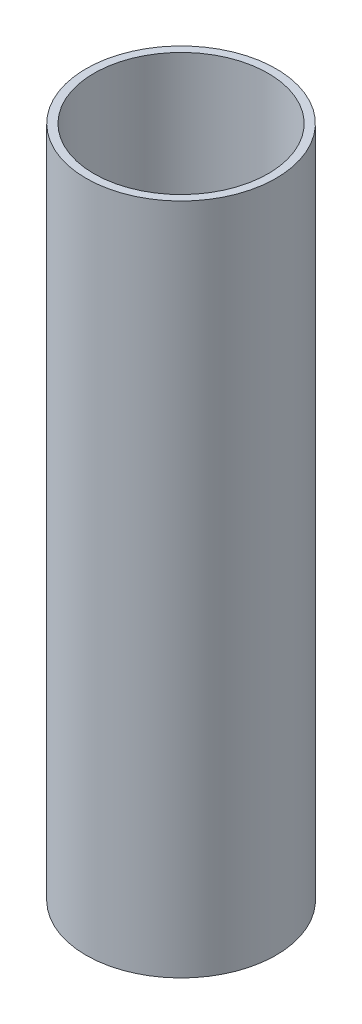
from build123d import *

# Parameters (mm, degrees)
SKETCH3_R           = 12
SKETCH3_R_2         = 11
BOSS_EXTRUDE3_DEPTH = 85


with BuildPart() as part:
    # Sketch3 → Boss-Extrude3 (new body)
    with BuildSketch(Plane(origin=(0, 0, 0), x_dir=(1, 0, 0), z_dir=(0, 1, 0))):
        Circle(SKETCH3_R)
        Circle(SKETCH3_R_2, mode=Mode.SUBTRACT)
    extrude(amount=BOSS_EXTRUDE3_DEPTH)


solid = part.part
